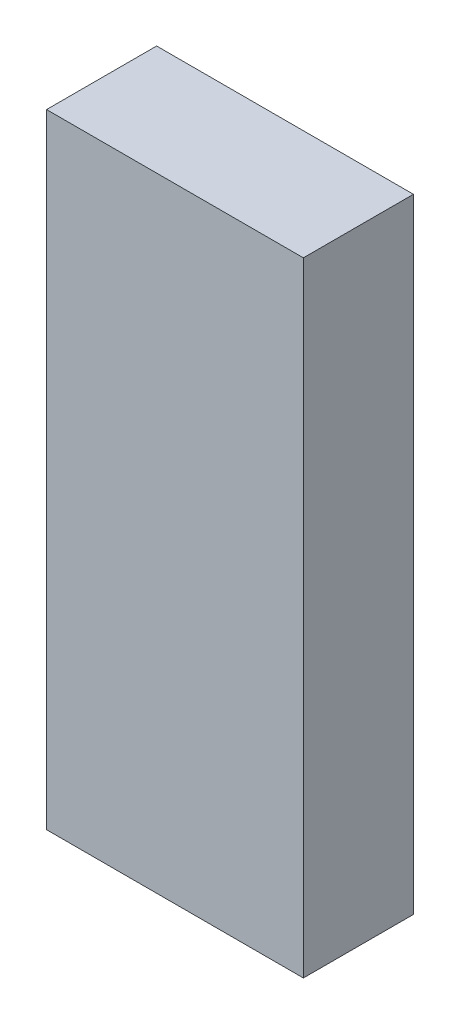
from build123d import *

# Parameters (mm, degrees)
SKETCH1_W           = 88.9
SKETCH1_H           = 38.1
BOSS_EXTRUDE1_DEPTH = 215.9


with BuildPart() as part:
    # Sketch1 → Boss-Extrude1 (new body)
    with BuildSketch(Plane(origin=(0, 0, 0), x_dir=(1, 0, 0), z_dir=(0, 1, 0))):
        Rectangle(SKETCH1_W, SKETCH1_H)
    extrude(amount=BOSS_EXTRUDE1_DEPTH)


solid = part.part
